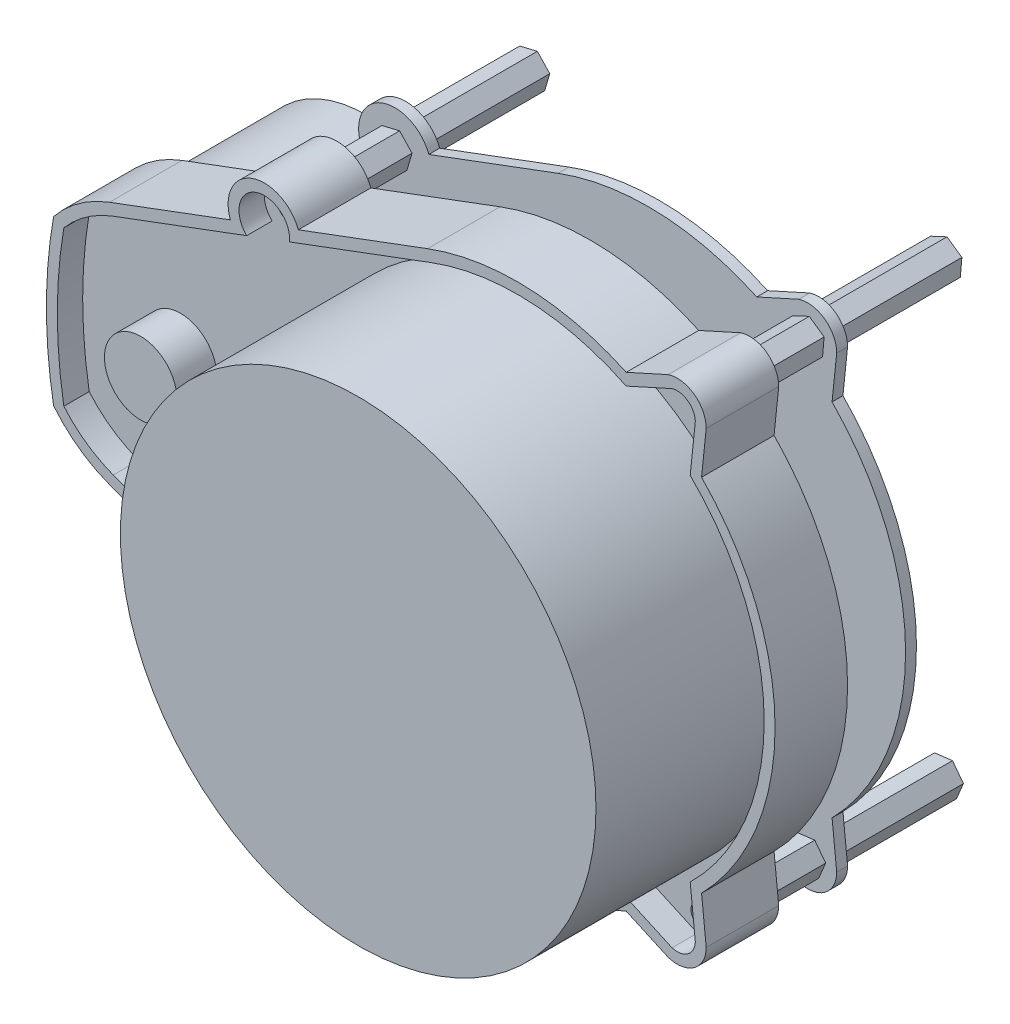
from build123d import *

# Parameters (mm, degrees)
ESQUISSE1_R             = 1.6
BOSS_EXTRU_1_DEPTH      = 10
ESQUISSE2_R             = 32.8
BOSS_EXTRU_2_DEPTH      = 22
ENL_V_MAT_EXTRU_1_DEPTH = 3.5
BOSS_EXTRU_3_REACH      = 12
ESQUISSE4_R             = 32.8
ESQUISSE5_R             = 16
BOSS_EXTRU_4_DEPTH      = 19
ESQUISSE6_R             = 1
BOSS_EXTRU_5_DEPTH      = 27
BOSS_EXTRU_6_DEPTH      = 1.5
ESQUISSE8_R             = 5
BOSS_EXTRU_7_DEPTH      = 5.5


with BuildPart() as part:
    # Esquisse1 → Boss.-Extru.1 (new body)
    with BuildSketch(Plane.XY):
        with BuildLine():
            ThreePointArc((-56.3, -16.861494596), (-60.528670487, -14.599558136), (-64.01, -11.301322931))
            ThreePointArc((-64.01, -11.301322931), (-65, 0), (-64.01, 11.301322931))
            ThreePointArc((-64.01, 11.301322931), (-60.528670487, 14.599558136), (-56.3, 16.861494596))
            Line((-56.3, 16.861494596), (-39.624688626, 23.091930519))
            ThreePointArc((-39.624688626, 23.091930519), (-36.690940127, 29.525679018), (-30.257191628, 26.591930519))
            Line((-30.257191628, 26.591930519), (-12.425, 33.254614341))
            ThreePointArc((-12.425, 33.254614341), (1.381675102, 35.473102119), (14.973963383, 32.187426436))
            Line((14.973963383, 32.187426436), (20.756023105, 34.801647207))
            ThreePointArc((20.756023105, 34.801647207), (24.347774736, 34.238511045), (26, 31))
            Line((26, 31), (25.359978077, 24.841930519))
            ThreePointArc((25.359978077, 24.841930519), (35.5, 0), (25.359978077, -24.841930519))
            Line((25.359978077, -24.841930519), (26, -31))
            ThreePointArc((26, -31), (24.347774736, -34.238511045), (20.756023105, -34.801647207))
            Line((20.756023105, -34.801647207), (14.973963383, -32.187426436))
            ThreePointArc((14.973963383, -32.187426436), (1.381675102, -35.473102119), (-12.425, -33.254614341))
            Line((-12.425, -33.254614341), (-30.257191628, -26.591930519))
            ThreePointArc((-30.257191628, -26.591930519), (-36.690940127, -29.525679018), (-39.624688626, -23.091930519))
            Line((-39.624688626, -23.091930519), (-56.3, -16.861494596))
        make_face()
        with Locations((-35, -25)):
            Circle(ESQUISSE1_R, mode=Mode.SUBTRACT)
        with Locations((22, 31)):
            Circle(ESQUISSE1_R, mode=Mode.SUBTRACT)
        with Locations((-35, 25)):
            Circle(ESQUISSE1_R, mode=Mode.SUBTRACT)
        with Locations((22, -31)):
            Circle(ESQUISSE1_R, mode=Mode.SUBTRACT)
    extrude(amount=BOSS_EXTRU_1_DEPTH)

    # Esquisse2 → Boss.-Extru.2 (add)
    with BuildSketch(Plane.XY.offset(10)):
        Circle(ESQUISSE2_R)
    extrude(amount=BOSS_EXTRU_2_DEPTH)

    # Esquisse3 → Enlèv. mat.-Extru.1 (cut)
    with BuildSketch(Plane.XY.offset(10)):
        with BuildLine():
            Line((-55.775, -15.456370046), (-37.378202776, -22.330008789))
            ThreePointArc((-37.378202776, -22.330008789), (-36.165940127, -28.120554469), (-31.453677478, -24.543603151))
            Line((-31.453677478, -24.543603151), (-11.9, -31.849489792))
            ThreePointArc((-11.9, -31.849489792), (1.664031028, -33.959255009), (14.956816294, -30.533484019))
            Line((14.956816294, -30.533484019), (21.291141631, -33.397398551))
            ThreePointArc((21.291141631, -33.397398551), (23.468656713, -33.023128137), (24.499056843, -31.06866508))
            Line((24.499056843, -31.06866508), (23.79417774, -24.286562245))
            ThreePointArc((23.79417774, -24.286562245), (34, 0), (23.79417774, 24.286562245))
            Line((23.79417774, 24.286562245), (24.499056843, 31.06866508))
            ThreePointArc((24.499056843, 31.06866508), (23.468656713, 33.023128137), (21.291141631, 33.397398551))
            Line((21.291141631, 33.397398551), (14.956816294, 30.533484019))
            ThreePointArc((14.956816294, 30.533484019), (1.664031028, 33.959255009), (-11.9, 31.849489792))
            Line((-11.9, 31.849489792), (-31.453677478, 24.543603151))
            ThreePointArc((-31.453677478, 24.543603151), (-36.165940127, 28.120554469), (-37.378202776, 22.330008789))
            Line((-37.378202776, 22.330008789), (-55.775, 15.456370046))
            ThreePointArc((-55.775, 15.456370046), (-59.496201473, 13.493411636), (-62.6, 10.653168543))
            ThreePointArc((-62.6, 10.653168543), (-63.5, 0), (-62.6, -10.653168543))
            ThreePointArc((-62.6, -10.653168543), (-59.496201473, -13.493411636), (-55.775, -15.456370046))
        make_face()
    extrude(amount=-ENL_V_MAT_EXTRU_1_DEPTH, mode=Mode.SUBTRACT)

    # Esquisse4 → Boss.-Extru.3 (add, up to next)
    with BuildSketch(Plane(origin=(0, 0, 10), x_dir=(-1, 0, 0), z_dir=(0, 0, -1)), mode=Mode.PRIVATE) as boss_extru_3_sk1:
        Circle(ESQUISSE4_R)
    boss_extru_3_tool1 = extrude(boss_extru_3_sk1.sketch, amount=BOSS_EXTRU_3_REACH, mode=Mode.PRIVATE) - part.part
    add(boss_extru_3_tool1.solids().sort_by_distance((0, 0, 10))[0])

    # Esquisse5 → Boss.-Extru.4 (add)
    with BuildSketch(Plane(origin=(0, 0, 0), x_dir=(-1, 0, 0), z_dir=(0, 0, -1))):
        with Locations((50, 0)):
            Circle(ESQUISSE5_R)
    extrude(amount=BOSS_EXTRU_4_DEPTH)

    # Esquisse6 → Boss.-Extru.5 (add)
    with BuildSketch(Plane(origin=(0, 0, 0), x_dir=(-1, 0, 0), z_dir=(0, 0, -1))):
        Polygon((-20.489225606, -29.008126327), (-22.969626005, -28.695694159), (-24.480400399, -30.687567832), (-23.510774394, -32.991873673), (-21.030373995, -33.304305841), (-19.519599601, -31.312432168), align=None)
        with Locations((-22, -31)):
            Circle(ESQUISSE6_R, mode=Mode.SUBTRACT)
        Polygon((36.086835018, -22.748602735), (33.593650283, -22.933074633), (32.506815266, -25.184471898), (33.913164982, -27.251397265), (36.406349717, -27.066925367), (37.493184734, -24.815528102), align=None)
        with Locations((35, -25)):
            Circle(ESQUISSE6_R, mode=Mode.SUBTRACT)
        Polygon((36.720274889, 26.814016072), (34.289153443, 27.396809791), (32.568878555, 25.582793719), (33.279725111, 23.185983928), (35.710846557, 22.603190209), (37.431121445, 24.417206281), align=None)
        with Locations((35, 25)):
            Circle(ESQUISSE6_R, mode=Mode.SUBTRACT)
        Polygon((-19.952160425, 32.43399898), (-22.217959758, 33.490480585), (-24.265799333, 32.056481605), (-24.047839575, 29.56600102), (-21.782040242, 28.509519415), (-19.734200667, 29.943518395), align=None)
        with Locations((-22, 31)):
            Circle(ESQUISSE6_R, mode=Mode.SUBTRACT)
    extrude(amount=BOSS_EXTRU_5_DEPTH)

    # Esquisse7 → Boss.-Extru.6 (add)
    with BuildSketch(Plane(origin=(0, 0, -8), x_dir=(-1, 0, 0), z_dir=(0, 0, -1))):
        with BuildLine():
            Line((30.257191628, 26.591930519), (12.425, 33.254614341))
            ThreePointArc((12.425, 33.254614341), (-1.381675102, 35.473102119), (-14.973963383, 32.187426436))
            Line((-14.973963383, 32.187426436), (-20.756023105, 34.801647207))
            ThreePointArc((-20.756023105, 34.801647207), (-24.347774736, 34.238511045), (-26, 31))
            Line((-26, 31), (-25.359978077, 24.841930519))
            ThreePointArc((-25.359978077, 24.841930519), (-35.5, 0), (-25.359978077, -24.841930519))
            Line((-25.359978077, -24.841930519), (-26, -31))
            ThreePointArc((-26, -31), (-24.347774736, -34.238511045), (-20.756023105, -34.801647207))
            Line((-20.756023105, -34.801647207), (-14.973963383, -32.187426436))
            ThreePointArc((-14.973963383, -32.187426436), (-1.381675102, -35.473102119), (12.425, -33.254614341))
            Line((12.425, -33.254614341), (30.257191628, -26.591930519))
            ThreePointArc((30.257191628, -26.591930519), (36.690940127, -29.525679018), (39.624688626, -23.091930519))
            ThreePointArc((39.624688626, -23.091930519), (33.487603548, 0), (39.624688626, 23.091930519))
            ThreePointArc((39.624688626, 23.091930519), (36.690940127, 29.525679018), (30.257191628, 26.591930519))
        make_face()
    extrude(amount=BOSS_EXTRU_6_DEPTH)

    # Esquisse8 → Boss.-Extru.7 (add)
    with BuildSketch(Plane.XY.offset(6.5)):
        with Locations((-50, 0)):
            Circle(ESQUISSE8_R)
    extrude(amount=BOSS_EXTRU_7_DEPTH)


solid = part.part
